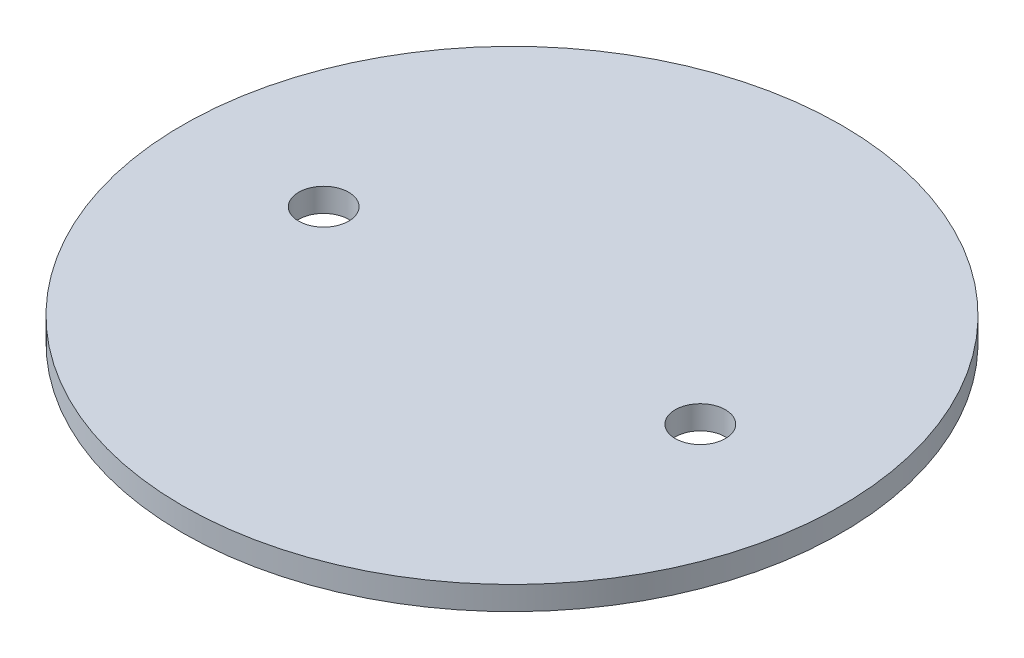
from build123d import *

# Parameters (mm, degrees)
SKETCH1_R               = 44.45
BOSS_EXTRUDE1_DEPTH     = 1.5875
F_1_4_CLEARANCE_HOLE1_D = 6.7564


with BuildPart() as part:
    # Sketch1 → Boss-Extrude1 (new body, symmetric)
    with BuildSketch(Plane(origin=(0, 0, 0), x_dir=(1, 0, 0), z_dir=(0, 1, 0))):
        Circle(SKETCH1_R)
    extrude(amount=BOSS_EXTRUDE1_DEPTH, both=True)

    # 1/4 Clearance Hole1 (through all)
    with Locations(Plane(origin=(0, 1.5875, 0), x_dir=(1, 0, 0), z_dir=(0, 1, 0))):
        with Locations((25.4, 0), (-25.4, 0)):
            Hole(F_1_4_CLEARANCE_HOLE1_D / 2)


solid = part.part
